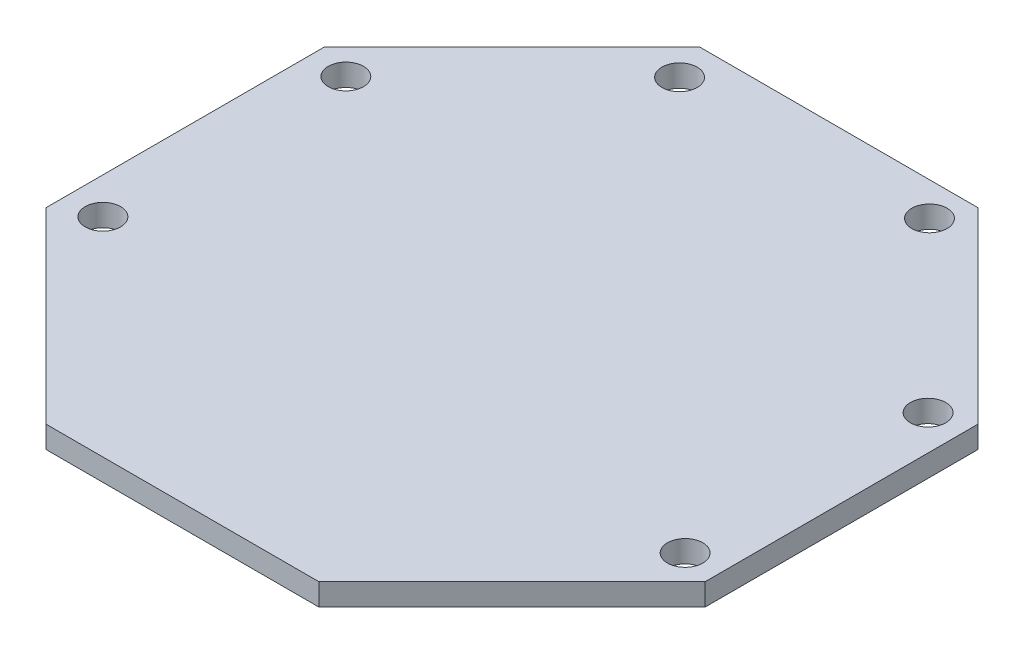
from build123d import *

# Parameters (mm, degrees)
SKETCH1_R           = 1.605500579
BOSS_EXTRUDE1_DEPTH = 2


with BuildPart() as part:
    # Sketch1 → Boss-Extrude1 (new body)
    with BuildSketch(Plane(origin=(0, 0, 0), x_dir=(1, 0, 0), z_dir=(0, 1, 0))):
        Polygon((41.878814697, 0), (17.049186707, 0), (0, 17.049188586), (0, 42.386817904), (17.049190507, 59.436044623), (42.386817918, 59.436044623), (59.436024652, 42.38683601), (59.436024652, 17.557208019), align=None)
        with Locations((56.261000782, 18.923025881)):
            Circle(SKETCH1_R, mode=Mode.SUBTRACT)
        with Locations((56.260999728, 41.021025454)):
            Circle(SKETCH1_R, mode=Mode.SUBTRACT)
        with Locations((41.020998031, 56.388025306)):
            Circle(SKETCH1_R, mode=Mode.SUBTRACT)
        with Locations((18.541997952, 56.134022616)):
            Circle(SKETCH1_R, mode=Mode.SUBTRACT)
        with Locations((3.302000809, 41.021022926)):
            Circle(SKETCH1_R, mode=Mode.SUBTRACT)
        with Locations((3.302001864, 18.923023353)):
            Circle(SKETCH1_R, mode=Mode.SUBTRACT)
    extrude(amount=BOSS_EXTRUDE1_DEPTH)


solid = part.part
